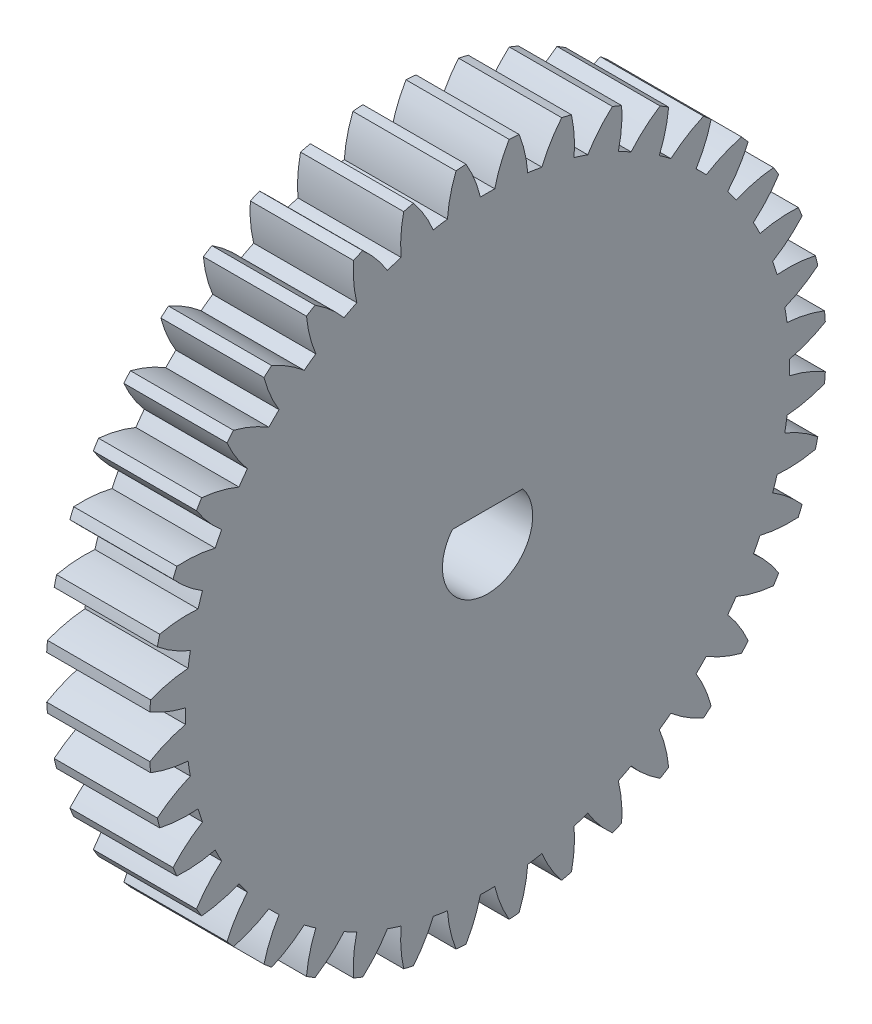
from build123d import *

# Parameters (mm, degrees)
BASPROSKE_W         = 8
BASPROSKE_H         = 26.25
TOOTHCUT_DEPTH      = 38.975320933
TEETHCUTS_COUNT     = 40
TEETHCUTS_ANGLE     = 351
BORSKE_R            = 3.5
BORE_DEPTH          = 50.0000508
BOSS_EXTRUDE1_DEPTH = 8


with BuildPart() as part:
    # BasProSke → Base-Revolve (revolve)
    with BuildSketch(Plane(origin=(0, 0, 0), x_dir=(1, 0, 0), z_dir=(0, 1, 0)), mode=Mode.PRIVATE) as base_revolve_sk:
        with Locations((4, 13.125)):
            Rectangle(BASPROSKE_W, BASPROSKE_H)
    revolve(base_revolve_sk.sketch.rotate(Axis((-10, 0, 0), (1, 0, 0)), 180), axis=Axis((-10, 0, 0), (1, 0, 0)))

    # TooCutSke → ToothCut (cut, through all)
    with BuildSketch(Plane(origin=(0, 0, 0), x_dir=(0, 0, -1), z_dir=(1, 0, 0))):
        with BuildLine():
            ThreePointArc((0.556797762, 23.429884944), (0, 23.4365), (-0.556797762, 23.429884944))
            ThreePointArc((-0.556797762, 23.429884944), (-1.015339965, 24.868305844), (-1.685200933, 26.221303228))
            ThreePointArc((-1.685200933, 26.221303228), (0, 26.2754), (1.685200933, 26.221303228))
            ThreePointArc((1.685200933, 26.221303228), (1.015339965, 24.868305844), (0.556797762, 23.429884944))
        make_face()
    toothcut = extrude(amount=TOOTHCUT_DEPTH, mode=Mode.SUBTRACT)

    # TeethCuts: ToothCut ×40 about axis
    teethcuts_axis = Axis((-10, 0, 0), (1, 0, 0))
    for i in range(1, TEETHCUTS_COUNT):
        add(toothcut.rotate(teethcuts_axis, i * TEETHCUTS_ANGLE / (TEETHCUTS_COUNT - 1)), mode=Mode.SUBTRACT)

    # BorSke → Bore (cut, symmetric)
    with BuildSketch(Plane(origin=(0, 0, 0), x_dir=(0, 0, -1), z_dir=(1, 0, 0))):
        with Locations(Location((0, 0, 0), (0, 0, 180))):
            Circle(BORSKE_R)
    extrude(amount=BORE_DEPTH, both=True, mode=Mode.SUBTRACT)

    # Sketch1 → Boss-Extrude1 (add)
    with BuildSketch(Plane(origin=(8, 0, 0), x_dir=(0, 0, -1), z_dir=(1, 0, 0))):
        with BuildLine():
            ThreePointArc((2.730503953, 2.1896), (0, 3.5), (-2.730503953, 2.1896))
            Line((-2.730503953, 2.1896), (2.730503953, 2.1896))
        make_face()
    extrude(amount=-BOSS_EXTRUDE1_DEPTH)


solid = part.part
